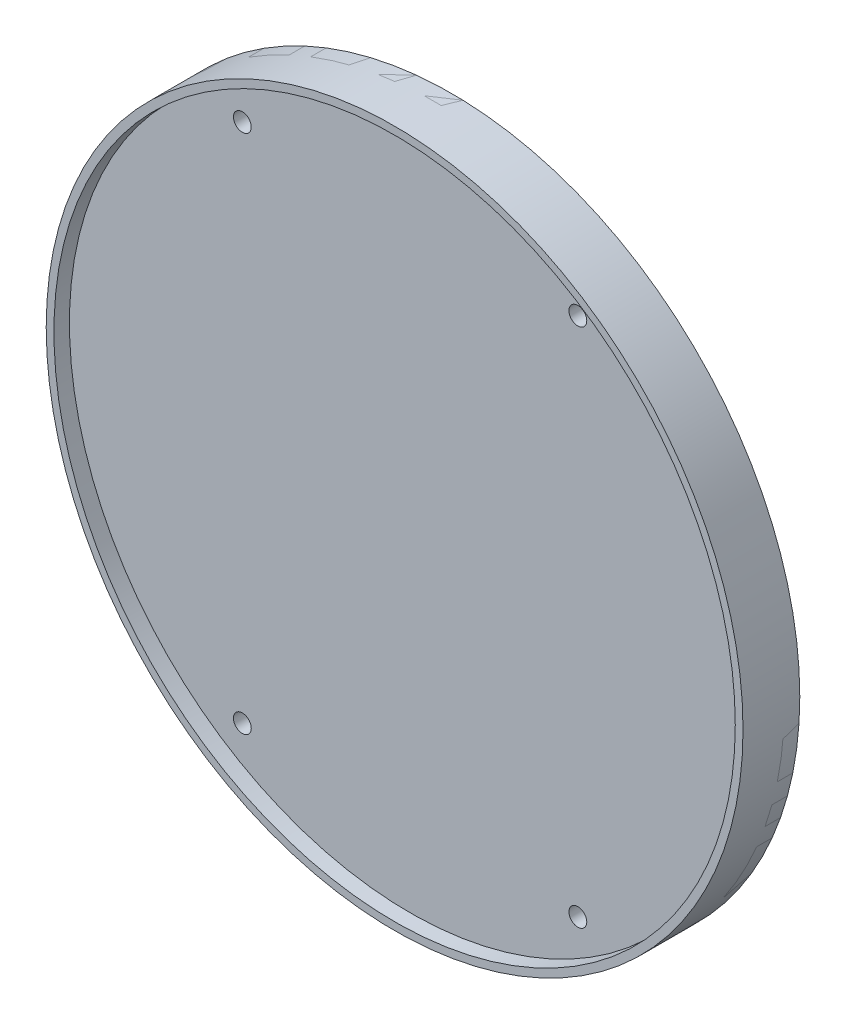
from build123d import *

# Parameters (mm, degrees)
SKETCH2_R                                     = 67.5
BOSS_EXTRUDE2_DEPTH                           = 11
SKETCH3_R                                     = 66
CUT_EXTRUDE11_DEPTH                           = 3
SKETCH15_R                                    = 66
CUT_EXTRUDE14_DEPTH                           = 3
SKETCH28_R                                    = 67.5
BOSS_EXTRUDE14_DEPTH                          = 3
CSK_FOR_5_FLAT_HEAD_SOCKET_CAP_SCREW5_A_COUNT = 2
CSK_FOR_5_FLAT_HEAD_SOCKET_CAP_SCREW5_A_PITCH = 65
CSK_FOR_5_FLAT_HEAD_SOCKET_CAP_SCRE_2_COUNT   = 2
CSK_FOR_5_FLAT_HEAD_SOCKET_CAP_SCRE_2_PITCH   = 120.000003622
CSK_FOR_5_FLAT_HEAD_SOCKET_CAP_SCRE_3_COUNT   = 2
CSK_FOR_5_FLAT_HEAD_SOCKET_CAP_SCRE_3_PITCH   = 100.871205009


with BuildPart() as part:
    # Sketch2 → Boss-Extrude2 (new body)
    with BuildSketch(Plane.XY):
        Circle(SKETCH2_R)
    extrude(amount=BOSS_EXTRUDE2_DEPTH)

    # Sketch3 → Cut-Extrude11 (cut)
    with BuildSketch(Plane(origin=(0, 0, 0), x_dir=(-1, 0, 0), z_dir=(0, 0, -1))):
        Circle(SKETCH3_R)
    extrude(amount=-CUT_EXTRUDE11_DEPTH, mode=Mode.SUBTRACT)

    # Sketch15 → Cut-Extrude14 (cut)
    with BuildSketch(Plane.XY.offset(11)):
        Circle(SKETCH15_R)
    extrude(amount=-CUT_EXTRUDE14_DEPTH, mode=Mode.SUBTRACT)


with BuildPart() as body_2:
    # Sketch28 → Boss-Extrude14 (new body)
    with BuildSketch(Plane(origin=(0, 0, 3), x_dir=(-1, 0, 0), z_dir=(0, 0, -1))):
        Circle(SKETCH28_R)
    extrude(amount=BOSS_EXTRUDE14_DEPTH)


with BuildPart() as csk_for_5_flat_head_socket_cap_screw5_tool:
    # Sketch30 → CSK for #5 Flat Head Socket Cap Screw5 (revolve)
    with BuildSketch(Plane(origin=(32.500003343, 50.435602505, 0), x_dir=(0, 1, 0), z_dir=(1, 0, 0))):
        Polygon((0, 0), (0, 69.377806461), (1.7272, 68.34), (1.7272, 2.118403422), (3.5687, 0), align=None)
    csk_for_5_flat_head_socket_cap_screw5 = revolve(axis=Axis((32.500003343, 50.435602505, -6.35), (0, 0, 1)))


with BuildPart() as part_1:
    add(part.part)

    # CSK for #5 Flat Head Socket Cap Screw5: cut by csk_for_5_flat_head_socket_cap_screw5_tool
    add(csk_for_5_flat_head_socket_cap_screw5_tool.part, mode=Mode.SUBTRACT)


with BuildPart() as body_2_1:
    add(body_2.part)

    # CSK for #5 Flat Head Socket Cap Screw5: cut by csk_for_5_flat_head_socket_cap_screw5_tool
    add(csk_for_5_flat_head_socket_cap_screw5_tool.part, mode=Mode.SUBTRACT)


with BuildPart() as csk_for_5_flat_head_socket_cap_screw5_a_tool:
    # CSK for #5 Flat Head Socket Cap Screw5 a: CSK for #5 Flat Head Socket Cap Screw5 ×2
    with Locations(*[(-i * CSK_FOR_5_FLAT_HEAD_SOCKET_CAP_SCREW5_A_PITCH, 0, 0) for i in range(1, CSK_FOR_5_FLAT_HEAD_SOCKET_CAP_SCREW5_A_COUNT)]):
        add(csk_for_5_flat_head_socket_cap_screw5)


with BuildPart() as part_2:
    add(part_1.part)

    # CSK for #5 Flat Head Socket Cap Screw5 a: cut by csk_for_5_flat_head_socket_cap_screw5_a_tool
    add(csk_for_5_flat_head_socket_cap_screw5_a_tool.part, mode=Mode.SUBTRACT)


with BuildPart() as body_2_2:
    add(body_2_1.part)

    # CSK for #5 Flat Head Socket Cap Screw5 a: cut by csk_for_5_flat_head_socket_cap_screw5_a_tool
    add(csk_for_5_flat_head_socket_cap_screw5_a_tool.part, mode=Mode.SUBTRACT)


with BuildPart() as csk_for_5_flat_head_socket_cap_scre_2_tool:
    # CSK for _5 Flat Head Socket Cap Scre 2: CSK for #5 Flat Head Socket Cap Screw5 ×2
    with Locations(*[Vector(-0.541666706, -0.84059335, 0) * (i * CSK_FOR_5_FLAT_HEAD_SOCKET_CAP_SCRE_2_PITCH) for i in range(1, CSK_FOR_5_FLAT_HEAD_SOCKET_CAP_SCRE_2_COUNT)]):
        add(csk_for_5_flat_head_socket_cap_screw5)


with BuildPart() as part_3:
    add(part_2.part)

    # CSK for _5 Flat Head Socket Cap Scre 2: cut by csk_for_5_flat_head_socket_cap_scre_2_tool
    add(csk_for_5_flat_head_socket_cap_scre_2_tool.part, mode=Mode.SUBTRACT)


with BuildPart() as body_2_3:
    add(body_2_2.part)

    # CSK for _5 Flat Head Socket Cap Scre 2: cut by csk_for_5_flat_head_socket_cap_scre_2_tool
    add(csk_for_5_flat_head_socket_cap_scre_2_tool.part, mode=Mode.SUBTRACT)


with BuildPart() as csk_for_5_flat_head_socket_cap_scre_3_tool:
    # CSK for _5 Flat Head Socket Cap Scre 3: CSK for #5 Flat Head Socket Cap Screw5 ×2
    with Locations(*[(0, -i * CSK_FOR_5_FLAT_HEAD_SOCKET_CAP_SCRE_3_PITCH, 0) for i in range(1, CSK_FOR_5_FLAT_HEAD_SOCKET_CAP_SCRE_3_COUNT)]):
        add(csk_for_5_flat_head_socket_cap_screw5)


with BuildPart() as part_4:
    add(part_3.part)

    # CSK for _5 Flat Head Socket Cap Scre 3: cut by csk_for_5_flat_head_socket_cap_scre_3_tool
    add(csk_for_5_flat_head_socket_cap_scre_3_tool.part, mode=Mode.SUBTRACT)


with BuildPart() as body_2_4:
    add(body_2_3.part)

    # CSK for _5 Flat Head Socket Cap Scre 3: cut by csk_for_5_flat_head_socket_cap_scre_3_tool
    add(csk_for_5_flat_head_socket_cap_scre_3_tool.part, mode=Mode.SUBTRACT)


solid = Compound([part_4.part, body_2_4.part])
